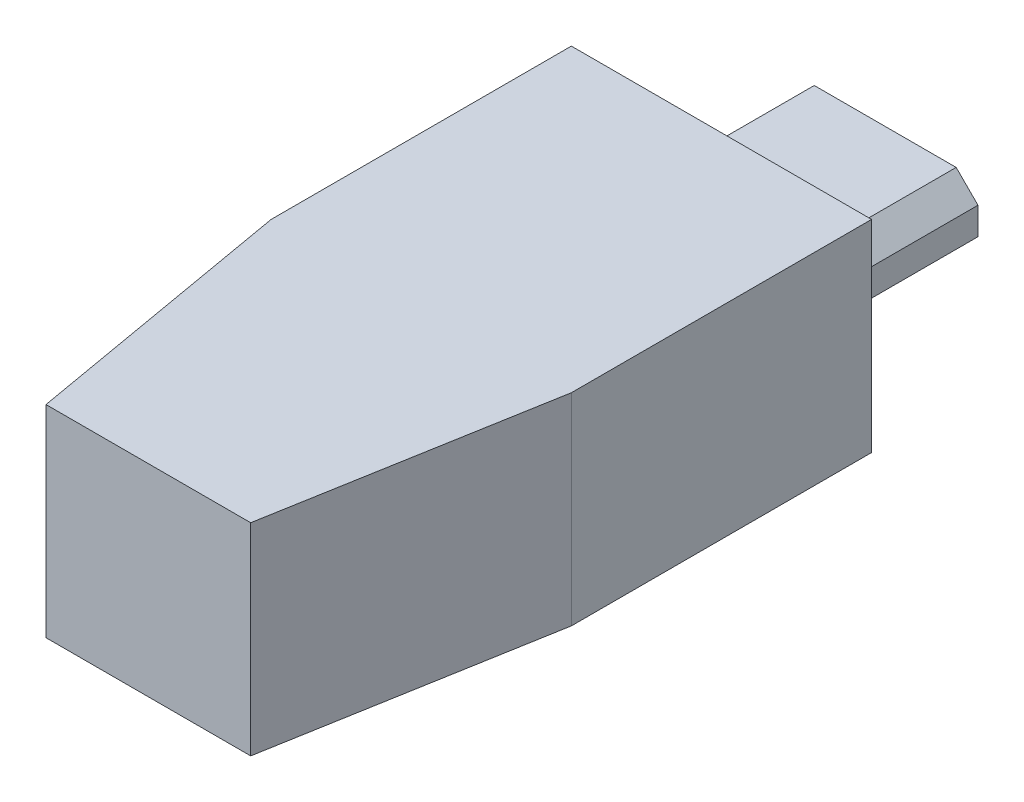
from build123d import *

# Parameters (mm, degrees)
SKICA1_W                 = 11
SKICA1_H                 = 7.4
P_IDAT_VYSUNUT_M1_DEPTH  = 21
ODEBRAT_VYSUNUT_M1_DEPTH = 21
P_IDAT_VYSUNUT_M2_DEPTH  = 6


with BuildPart() as part:
    # Skica1 → Přidat vysunutím1 (new body)
    with BuildSketch(Plane.XY):
        Rectangle(SKICA1_W, SKICA1_H)
    extrude(amount=P_IDAT_VYSUNUT_M1_DEPTH)

    # Skica2 → Odebrat vysunutím1 (cut)
    with BuildSketch(Plane(origin=(0, 3.7, 0), x_dir=(1, 0, 0), z_dir=(0, 1, 0))):
        Polygon((-5.5, -11), (-3.75, -21), (3.75, -21), (5.5, -11), (8.02176331, -11), (9.220966656, -26.189909052), (-8.647163202, -26.189909052), align=None)
    extrude(amount=-ODEBRAT_VYSUNUT_M1_DEPTH, mode=Mode.SUBTRACT)

    # Skica3 → Přidat vysunutím2 (add)
    with BuildSketch(Plane(origin=(0, 0, 0), x_dir=(-1, 0, 0), z_dir=(0, 0, -1))):
        Polygon((-3.4, 0.1), (-2.6, 0.9), (2.6, 0.9), (3.4, 0.1), (3.4, -0.9), (-3.4, -0.9), align=None)
    extrude(amount=P_IDAT_VYSUNUT_M2_DEPTH)


solid = part.part
